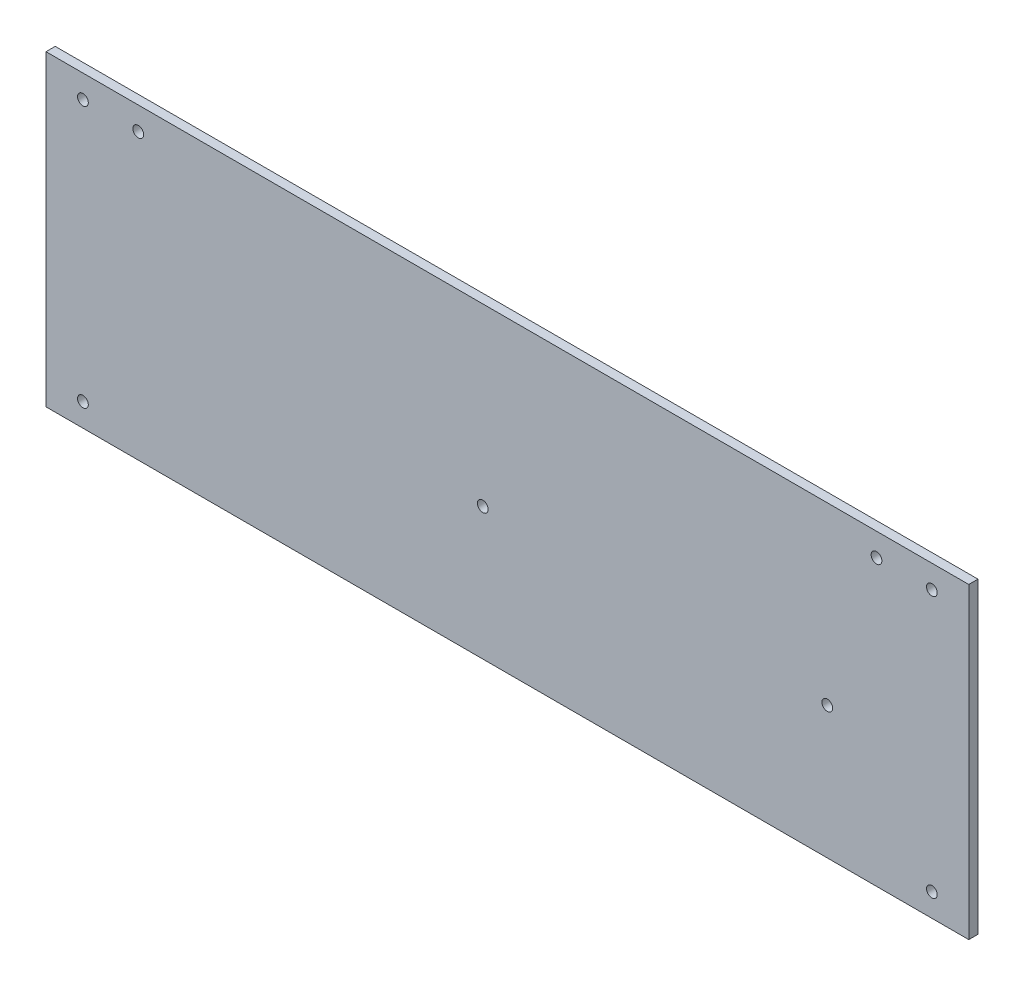
from build123d import *

# Parameters (mm, degrees)
SKETCH1_W           = 300
SKETCH1_H           = 100
BOSS_EXTRUDE1_DEPTH = 3
SKETCH6_R           = 1.75
CUT_EXTRUDE5_DEPTH  = 30
SKETCH7_R           = 1.75
CUT_EXTRUDE6_DEPTH  = 10


with BuildPart() as part:
    # Sketch1 → Boss-Extrude1 (new body)
    with BuildSketch(Plane.XY):
        with Locations((150, 50)):
            Rectangle(SKETCH1_W, SKETCH1_H)
    extrude(amount=BOSS_EXTRUDE1_DEPTH)

    # Sketch6 → Cut-Extrude5 (cut)
    with BuildSketch(Plane.XY.offset(3)):
        with Locations((142, 43)):
            Circle(SKETCH6_R)
        with Locations((254, 43)):
            Circle(SKETCH6_R)
    extrude(amount=-CUT_EXTRUDE5_DEPTH, mode=Mode.SUBTRACT)

    # Sketch7 → Cut-Extrude6 (cut)
    with BuildSketch(Plane(origin=(0, 0, 0), x_dir=(-1, 0, 0), z_dir=(0, 0, -1))):
        with Locations((-288, 92.5)):
            Circle(SKETCH7_R)
        with Locations((-270, 92.5)):
            Circle(SKETCH7_R)
        with Locations((-288, 7.5)):
            Circle(SKETCH7_R)
        with Locations((-12, 7.5)):
            Circle(SKETCH7_R)
        with Locations((-12, 92.5)):
            Circle(SKETCH7_R)
        with Locations((-30, 92.5)):
            Circle(SKETCH7_R)
    extrude(amount=-CUT_EXTRUDE6_DEPTH, mode=Mode.SUBTRACT)


solid = part.part
